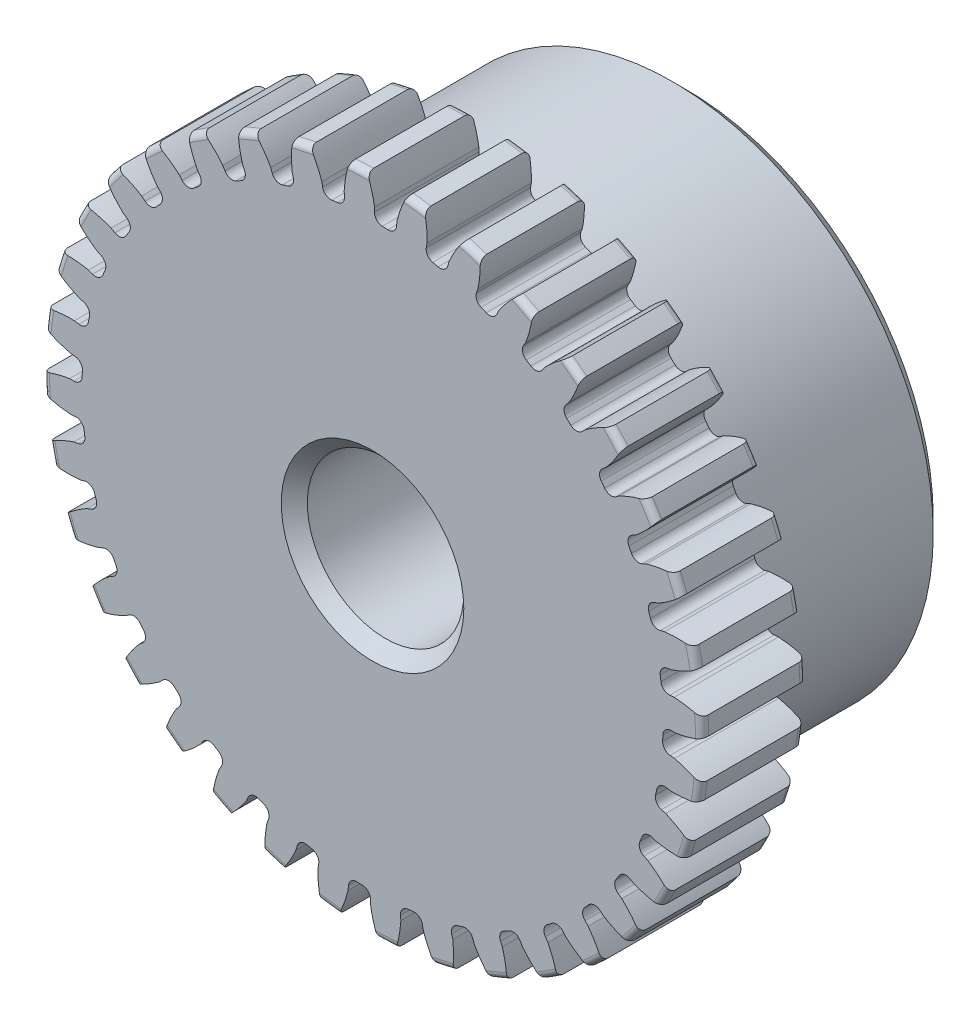
from build123d import *

# Parameters (mm, degrees)
SKETCH1_R                = 10.033
BOSS_EXTRUDE1_DEPTH      = 3.175
SKETCH2_W                = 6.35
SKETCH2_H                = 7.9375
FILLET2_R                = 0.20066
CUT_EXTRUDE1_DEPTH       = 10.525
FILLET1_R                = 0.2493645
CIRPATTERN1_COUNT        = 36
FILLET1_OF_CIRPATTERN1_R = 0.2493645
SKETCH5_R                = 2.38125
CUT_EXTRUDE2_DEPTH       = 10.525
CHAMFER1_SIZE            = 0.396875


with BuildPart() as part:
    # Sketch1 → Boss-Extrude1 (new body)
    with BuildSketch(Plane.XY):
        Circle(SKETCH1_R)
    extrude(amount=-BOSS_EXTRUDE1_DEPTH)

    # Sketch2 → Revolve1 (revolve)
    with BuildSketch(Plane(origin=(0, 0, 0), x_dir=(0, 0, -1), z_dir=(1, 0, 0))):
        with Locations((6.35, 3.96875)):
            Rectangle(SKETCH2_W, SKETCH2_H)
    revolve(axis=Axis((0, 0, -3.175), (0, 0, -1)))

    # Fillet2
    fillet2_edges = [part.edges().sort_by_distance(p)[0] for p in [
        (-10.033, 0, 0),
        (-10.033, 0, -3.175),
        (0, -7.9375, -3.175),
    ]]
    fillet(fillet2_edges, radius=FILLET2_R)

    # Sketch4 → Cut-Extrude1 (cut, through all)
    with BuildSketch(Plane.XY):
        with BuildLine():
            Line((0.059789782, 9.221412444), (0.059789782, 8.842172856))
            ThreePointArc((0.059789782, 8.842172856), (0.385699882, 8.833958979), (0.711085677, 8.813736597))
            Line((0.711085677, 8.813736597), (0.744138662, 9.191533057))
            add(Edge.make_bspline(
                [(1.925627404, 11.06644214), (1.006265756, 10.2763616), (0.744138662, 9.191533057)],
                knots=[0, 0, 0, 1, 1, 1], degree=2))
            ThreePointArc((1.925627404, 11.06644214), (0.489965867, 11.222037069), (-0.953793542, 11.192160668))
            add(Edge.make_bspline(
                [(-0.953793542, 11.192160668), (-0.106790576, 10.324958803), (0.059789782, 9.221412444)],
                knots=[0, 0, 0, 1, 1, 1], degree=2))
        make_face()
    cut_extrude1 = extrude(amount=-CUT_EXTRUDE1_DEPTH, mode=Mode.SUBTRACT)

    # Fillet1
    fillet1_edges = [part.edges().sort_by_distance(p)[0] for p in [
        (0.711085677, 8.813736597, -1.5875),
        (0.059789782, 8.842172856, -1.5875),
    ]]
    fillet(fillet1_edges, radius=FILLET1_R)

    # CirPattern1: Cut-Extrude1 ×36 about axis
    cirpattern1_axis = Axis((0, 0, -3.175), (0, 0, 1))
    for i in range(1, CIRPATTERN1_COUNT):
        add(cut_extrude1.rotate(cirpattern1_axis, i * 360 / CIRPATTERN1_COUNT), mode=Mode.SUBTRACT)

    # Fillet1 of CirPattern1
    fillet1_of_cirpattern1_edges = [part.edges().sort_by_distance(p)[0] for p in [
        (-0.83020661, 8.803314866, -1.5875),
        (-1.476545762, 8.718222769, -1.5875),
        (-2.34627349, 8.525408867, -1.5875),
        (-2.968017211, 8.329373895, -1.5875),
        (-3.791050038, 7.988462634, -1.5875),
        (-4.369306958, 7.687441209, -1.5875),
        (-5.120637448, 7.208791006, -1.5875),
        (-5.637837524, 6.811929513, -1.5875),
        (-6.29463688, 6.210083911, -1.5875),
        (-6.735065251, 5.729440785, -1.5875),
        (-7.277376957, 5.022686559, -1.5875),
        (-7.627651427, 4.472865898, -1.5875),
        (-8.038997616, 3.682677418, -1.5875),
        (-8.288475275, 3.080385245, -1.5875),
        (-8.556357402, 2.230771987, -1.5875),
        (-8.697457996, 1.594308644, -1.5875),
        (-8.813736597, 0.711085677, -1.5875),
        (-8.842172856, 0.059789782, -1.5875),
        (-8.803314866, -0.83020661, -1.5875),
        (-8.718222769, -1.476545762, -1.5875),
        (-8.525408867, -2.34627349, -1.5875),
        (-8.329373895, -2.968017211, -1.5875),
        (-7.988462634, -3.791050038, -1.5875),
        (-7.687441209, -4.369306958, -1.5875),
        (-7.208791006, -5.120637448, -1.5875),
        (-6.811929513, -5.637837524, -1.5875),
        (-6.210083911, -6.29463688, -1.5875),
        (-5.729440785, -6.735065251, -1.5875),
        (-5.022686559, -7.277376957, -1.5875),
        (-4.472865898, -7.627651427, -1.5875),
        (-3.682677418, -8.038997616, -1.5875),
        (-3.080385245, -8.288475275, -1.5875),
        (-2.230771987, -8.556357402, -1.5875),
        (-1.594308644, -8.697457996, -1.5875),
        (-0.711085677, -8.813736597, -1.5875),
        (-0.059789782, -8.842172856, -1.5875),
        (0.83020661, -8.803314866, -1.5875),
        (1.476545762, -8.718222769, -1.5875),
        (2.34627349, -8.525408867, -1.5875),
        (2.968017211, -8.329373895, -1.5875),
        (3.791050038, -7.988462634, -1.5875),
        (4.369306958, -7.687441209, -1.5875),
        (5.120637448, -7.208791006, -1.5875),
        (5.637837524, -6.811929513, -1.5875),
        (6.29463688, -6.210083911, -1.5875),
        (6.735065251, -5.729440785, -1.5875),
        (7.277376957, -5.022686559, -1.5875),
        (7.627651427, -4.472865898, -1.5875),
        (8.038997616, -3.682677418, -1.5875),
        (8.288475275, -3.080385245, -1.5875),
        (8.556357402, -2.230771987, -1.5875),
        (8.697457996, -1.594308644, -1.5875),
        (8.813736597, -0.711085677, -1.5875),
        (8.842172856, -0.059789782, -1.5875),
        (8.803314866, 0.83020661, -1.5875),
        (8.718222769, 1.476545762, -1.5875),
        (8.525408867, 2.34627349, -1.5875),
        (8.329373895, 2.968017211, -1.5875),
        (7.988462634, 3.791050038, -1.5875),
        (7.687441209, 4.369306958, -1.5875),
        (7.208791006, 5.120637448, -1.5875),
        (6.811929513, 5.637837524, -1.5875),
        (6.210083911, 6.29463688, -1.5875),
        (5.729440785, 6.735065251, -1.5875),
        (5.022686559, 7.277376957, -1.5875),
        (4.472865898, 7.627651427, -1.5875),
        (3.682677418, 8.038997616, -1.5875),
        (3.080385245, 8.288475275, -1.5875),
        (2.230771987, 8.556357402, -1.5875),
        (1.594308644, 8.697457996, -1.5875),
    ]]
    fillet(fillet1_of_cirpattern1_edges, radius=FILLET1_OF_CIRPATTERN1_R)

    # Sketch5 → Cut-Extrude2 (cut, through all)
    with BuildSketch(Plane.XY):
        Circle(SKETCH5_R)
    extrude(amount=-CUT_EXTRUDE2_DEPTH, mode=Mode.SUBTRACT)

    # Chamfer1
    chamfer1_edges = [part.edges().sort_by_distance(p)[0] for p in [
        (-2.38125, 0, -9.525),
        (-2.38125, 0, 0),
        (0, -7.9375, -9.525),
    ]]
    chamfer(chamfer1_edges, length=CHAMFER1_SIZE)


solid = part.part
